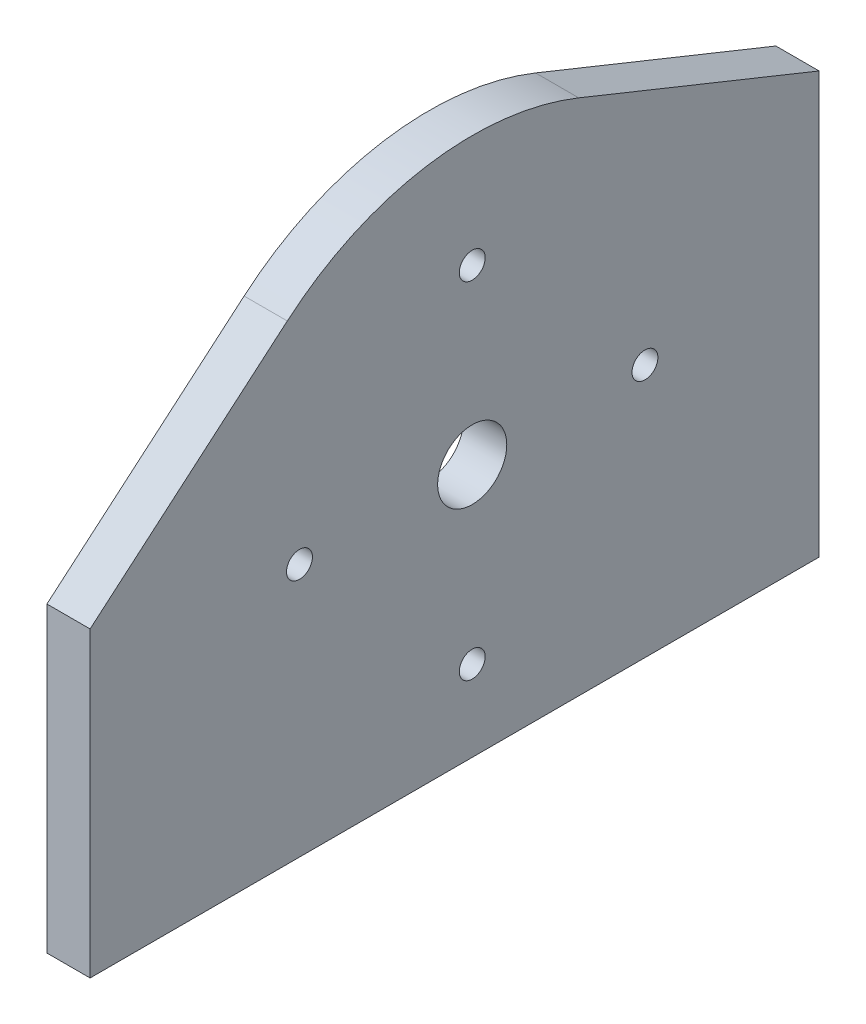
from build123d import *

# Parameters (mm, degrees)
ESTRUSIONE_ESTRUSIONE1_DEPTH = 5
SCHIZZO2_R                   = 4
SCHIZZO2_R_2                 = 1.5
TAGLIO_ESTRUSIONE1_DEPTH     = 6


with BuildPart() as part:
    # Schizzo3 → Estrusione-Estrusione1 (new body)
    with BuildSketch(Plane(origin=(0, 0, 0), x_dir=(0, 0, -1), z_dir=(1, 0, 0))):
        with BuildLine():
            Line((40.160183768, 51.647051924), (40.160183768, 100.394835388))
            Line((40.160183768, 100.394835388), (12.334616938, 111.608123513))
            ThreePointArc((12.334616938, 111.608123513), (-5.305430843, 113.570729245), (-21.410737295, 106.111358555))
            Line((-21.410737295, 106.111358555), (-44.239245072, 86.647051924))
            Line((-44.239245072, 86.647051924), (-44.239245072, 51.647051924))
            Line((-44.239245072, 51.647051924), (40.160183768, 51.647051924))
        make_face()
    extrude(amount=ESTRUSIONE_ESTRUSIONE1_DEPTH)

    # Schizzo2 → Taglio-Estrusione1 (cut, through all)
    with BuildSketch(Plane(origin=(0, 0, 0), x_dir=(0, 0, -1), z_dir=(1, 0, 0))):
        with Locations((-95, 0)):
            Circle(SCHIZZO2_R)
        with Locations((201, 0)):
            Circle(SCHIZZO2_R)
        with Locations((0, 101)):
            Circle(SCHIZZO2_R_2)
        with Locations((0, 61)):
            Circle(SCHIZZO2_R_2)
        with Locations((20, 81)):
            Circle(SCHIZZO2_R_2)
        with Locations((-20, 81)):
            Circle(SCHIZZO2_R_2)
        with Locations((0, 81)):
            Circle(SCHIZZO2_R)
    extrude(amount=TAGLIO_ESTRUSIONE1_DEPTH, mode=Mode.SUBTRACT)


solid = part.part
